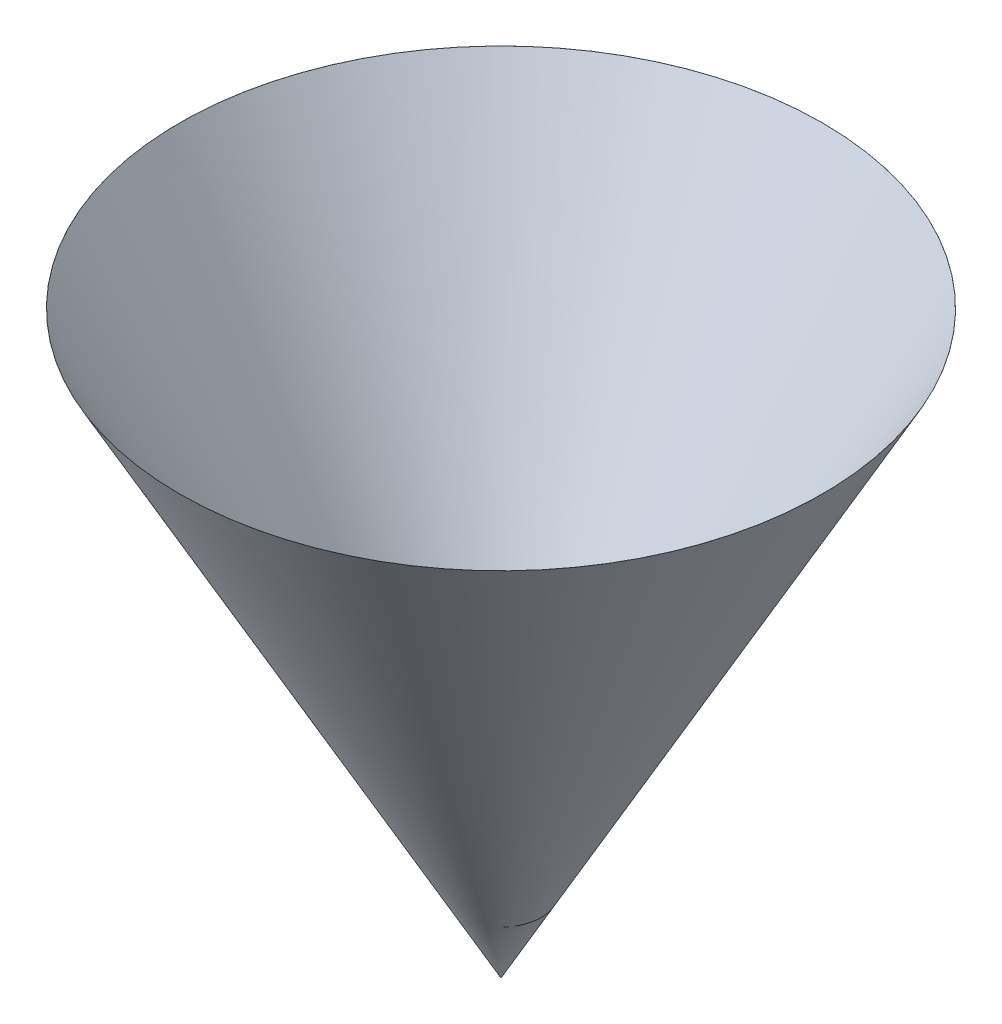
from build123d import *


with BuildPart() as part:
    # 草图2 → 旋转1 (revolve)
    with BuildSketch(Plane(origin=(0, 0, 0), x_dir=(0, 0, -1), z_dir=(1, 0, 0))):
        Polygon((0, 0), (83.146357718, 150), (83.136357718, 150), (0, 0.018040478), align=None)
    revolve(axis=Axis((0, 0, 0), (0, 1, 0)))


solid = part.part
